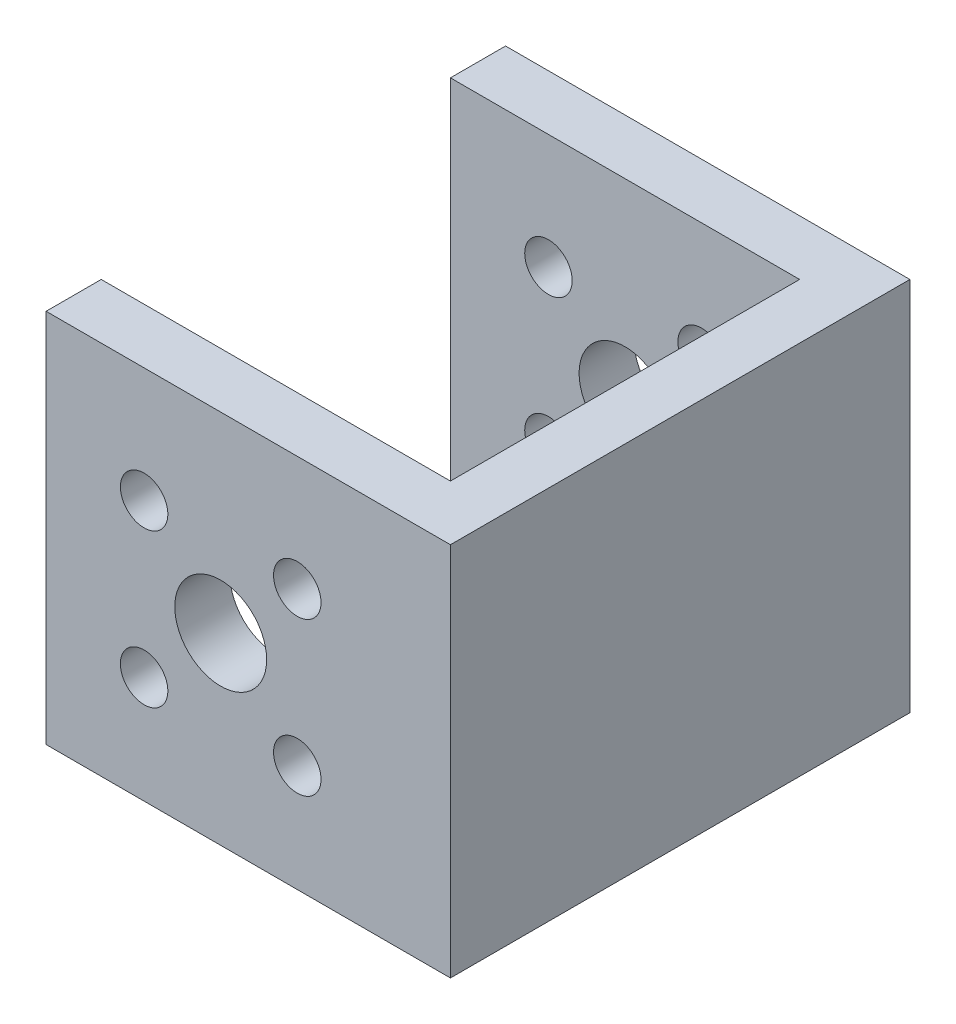
from build123d import *

# Parameters (mm, degrees)
SKETCH_1_R          = 3
SKETCH_1_R_2        = 1.55
EXTRUDE_1_DEPTH     = 30
CUT_EXTRUDE_1_DEPTH = 37.5
SKETCH_4_W          = 30
SKETCH_4_H          = 30
CUT_EXTRUDE_3_DEPTH = 12
EXTRUDE_2_DEPTH     = 55
SKETCH_6_R          = 2.3
SKETCH_6_R_2        = 5
SKETCH_6_R_3        = 6
SKETCH_6_R_4        = 4
CUT_EXTRUDE_4_DEPTH = 25.5
FILLET_2_R          = 2
CUT_EXTRUDE_5_DEPTH = 25.5


with BuildPart() as part:
    # 草图1 → 凸台-拉伸1 (new body)
    with BuildSketch(Plane.XY):
        Polygon((15, 0), (15, 12.5), (0, 12.5), (-15, 12.5), (-15, -24), (15, -24), align=None)
        Circle(SKETCH_1_R, mode=Mode.SUBTRACT)
        with Locations((-5, 5)):
            Circle(SKETCH_1_R_2, mode=Mode.SUBTRACT)
        with Locations((-5, -5)):
            Circle(SKETCH_1_R_2, mode=Mode.SUBTRACT)
        with Locations((5, -5)):
            Circle(SKETCH_1_R_2, mode=Mode.SUBTRACT)
        with Locations((5, 5)):
            Circle(SKETCH_1_R_2, mode=Mode.SUBTRACT)
    extrude(amount=EXTRUDE_1_DEPTH)

    # 草图2 → 切除-拉伸1 (cut, through all)
    with BuildSketch(Plane(origin=(0, 12.5, 0), x_dir=(1, 0, 0), z_dir=(0, 1, 0))):
        Polygon((-11.4, -15), (-11.4, -3.6), (0, -3.6), (11.4, -3.6), (11.4, -26.4), (0, -26.4), (-11.4, -26.4), align=None)
    extrude(amount=-CUT_EXTRUDE_1_DEPTH, mode=Mode.SUBTRACT)

    # 草图4 → 切除-拉伸3 (cut)
    with BuildSketch(Plane.XZ.offset(24)):
        with Locations((0, 15)):
            Rectangle(SKETCH_4_W, SKETCH_4_H)
    extrude(amount=-CUT_EXTRUDE_3_DEPTH, mode=Mode.SUBTRACT)

    # 草图5 → 凸台-拉伸2 (add)
    with BuildSketch(Plane.ZY.offset(15)):
        Polygon((30, -12), (30, 11.596689914), (30, 12.5), (0, 12.5), (0, -12), align=None)
    extrude(amount=EXTRUDE_2_DEPTH)

    # 草图6 → 切除-拉伸4 (cut, through all)
    with BuildSketch(Plane(origin=(0, 12.5, 0), x_dir=(1, 0, 0), z_dir=(0, 1, 0))):
        Polygon((-70, -15), (-11.4, 0), (-70, 0), align=None)
        Polygon((-11.4, -30), (-70, -15), (-70, -30), align=None)
        with Locations((-56.4, -15)):
            Circle(SKETCH_6_R)
        with Locations((-33.9, -15)):
            Circle(SKETCH_6_R_2)
        with Locations((-22.125549979, -15)):
            Circle(SKETCH_6_R_3)
        with Locations((-46.110471912, -15)):
            Circle(SKETCH_6_R_4)
    extrude(amount=-CUT_EXTRUDE_4_DEPTH, mode=Mode.SUBTRACT)

    # 圆角2
    fillet_2_edges = [part.edges().sort_by_distance(p)[0] for p in [
        (-70, 0.25, 15),
    ]]
    fillet(fillet_2_edges, radius=FILLET_2_R)

    # 草图7 → 切除-拉伸5 (cut, through all)
    with BuildSketch(Plane(origin=(0, 12.5, 0), x_dir=(1, 0, 0), z_dir=(0, 1, 0))):
        Polygon((-11.4, -3.6), (-11.4, 0), (-66.954884603, 0), (-66.4, -30), (-11.4, -30), align=None)
    extrude(amount=-CUT_EXTRUDE_5_DEPTH, mode=Mode.SUBTRACT)


solid = part.part
